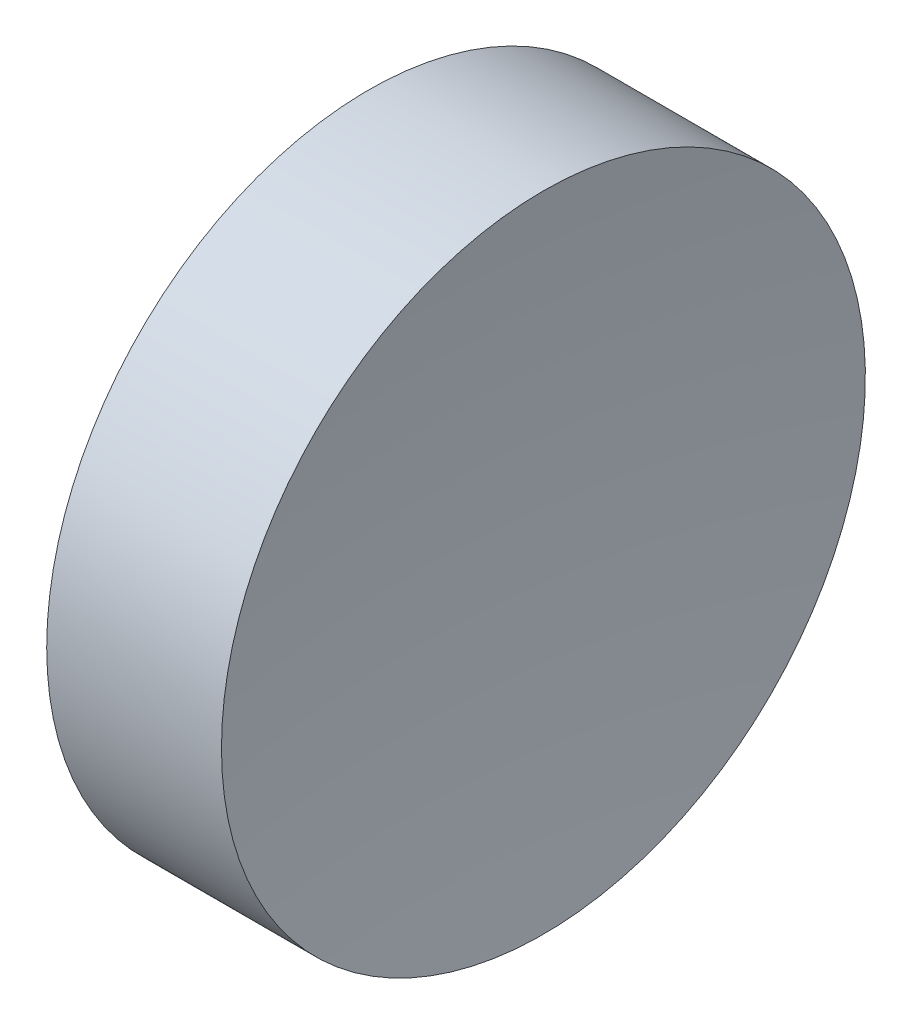
from build123d import *


with BuildPart() as part:
    # 草图1 → 旋转1 (revolve)
    with BuildSketch(Plane.XY):
        with BuildLine():
            Line((22.172189475, 13.044520575), (22.172189475, 16.194520575))
            Line((22.172189475, 16.194520575), (23.882189475, 16.194520575))
            ThreePointArc((23.882189475, 16.194520575), (23.724766394, 14.623015864), (23.672214456, 13.044520575))
            Line((23.672214456, 13.044520575), (22.172189475, 13.044520575))
        make_face()
    revolve(axis=Axis((21.224930557, 13.044520575, 0), (1, 0, 0)))


solid = part.part
